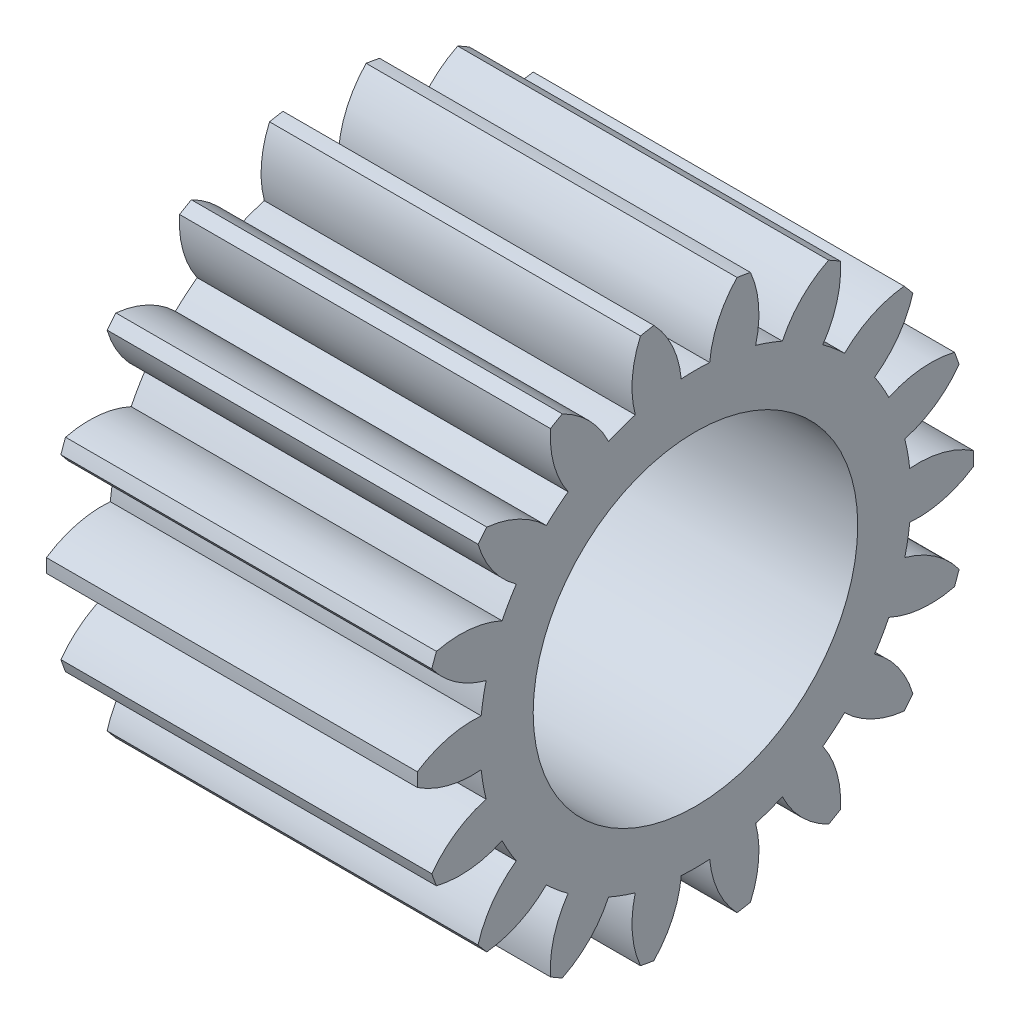
from build123d import *

# Parameters (mm, degrees)
BASPROSKE_W        = 8
BASPROSKE_H        = 6
TOOTHCUT_DEPTH     = 12.66190379
TEETHCUTS_COUNT    = 18
TEETHCUTS_ANGLE    = 340
BORSKE_R           = 0.5
BORE_DEPTH         = 50.0000508
SKETCH1_R          = 3.5
CUT_EXTRUDE1_DEPTH = 12.627390673


with BuildPart() as part:
    # BasProSke → Base-Revolve (revolve)
    with BuildSketch(Plane(origin=(0, 0, 0), x_dir=(1, 0, 0), z_dir=(0, 1, 0)), mode=Mode.PRIVATE) as base_revolve_sk:
        with Locations((4, 3)):
            Rectangle(BASPROSKE_W, BASPROSKE_H)
    revolve(base_revolve_sk.sketch.rotate(Axis((-10, 0, 0), (1, 0, 0)), 180), axis=Axis((-10, 0, 0), (1, 0, 0)))

    # TooCutSke → ToothCut (cut, through all)
    with BuildSketch(Plane(origin=(0, 0, 0), x_dir=(0, 0, -1), z_dir=(1, 0, 0))):
        with BuildLine():
            ThreePointArc((0.306649621, 4.638875619), (0, 4.649), (-0.306649621, 4.638875619))
            ThreePointArc((-0.306649621, 4.638875619), (-0.498605842, 5.349852231), (-0.918258882, 5.955018538))
            ThreePointArc((-0.918258882, 5.955018538), (0, 6.0254), (0.918258882, 5.955018538))
            ThreePointArc((0.918258882, 5.955018538), (0.498605842, 5.349852231), (0.306649621, 4.638875619))
        make_face()
    toothcut = extrude(amount=TOOTHCUT_DEPTH, mode=Mode.SUBTRACT)

    # TeethCuts: ToothCut ×18 about axis
    teethcuts_axis = Axis((-10, 0, 0), (1, 0, 0))
    for i in range(1, TEETHCUTS_COUNT):
        add(toothcut.rotate(teethcuts_axis, i * TEETHCUTS_ANGLE / (TEETHCUTS_COUNT - 1)), mode=Mode.SUBTRACT)

    # BorSke → Bore (cut, symmetric)
    with BuildSketch(Plane(origin=(0, 0, 0), x_dir=(0, 0, -1), z_dir=(1, 0, 0))):
        with Locations(Location((0, 0, 0), (0, 0, 180))):
            Circle(BORSKE_R)
    extrude(amount=BORE_DEPTH, both=True, mode=Mode.SUBTRACT)

    # Sketch1 → Cut-Extrude1 (cut, through all)
    with BuildSketch(Plane(origin=(8, 0, 0), x_dir=(0, 0, -1), z_dir=(1, 0, 0))):
        Circle(SKETCH1_R)
    extrude(amount=-CUT_EXTRUDE1_DEPTH, mode=Mode.SUBTRACT)


solid = part.part
